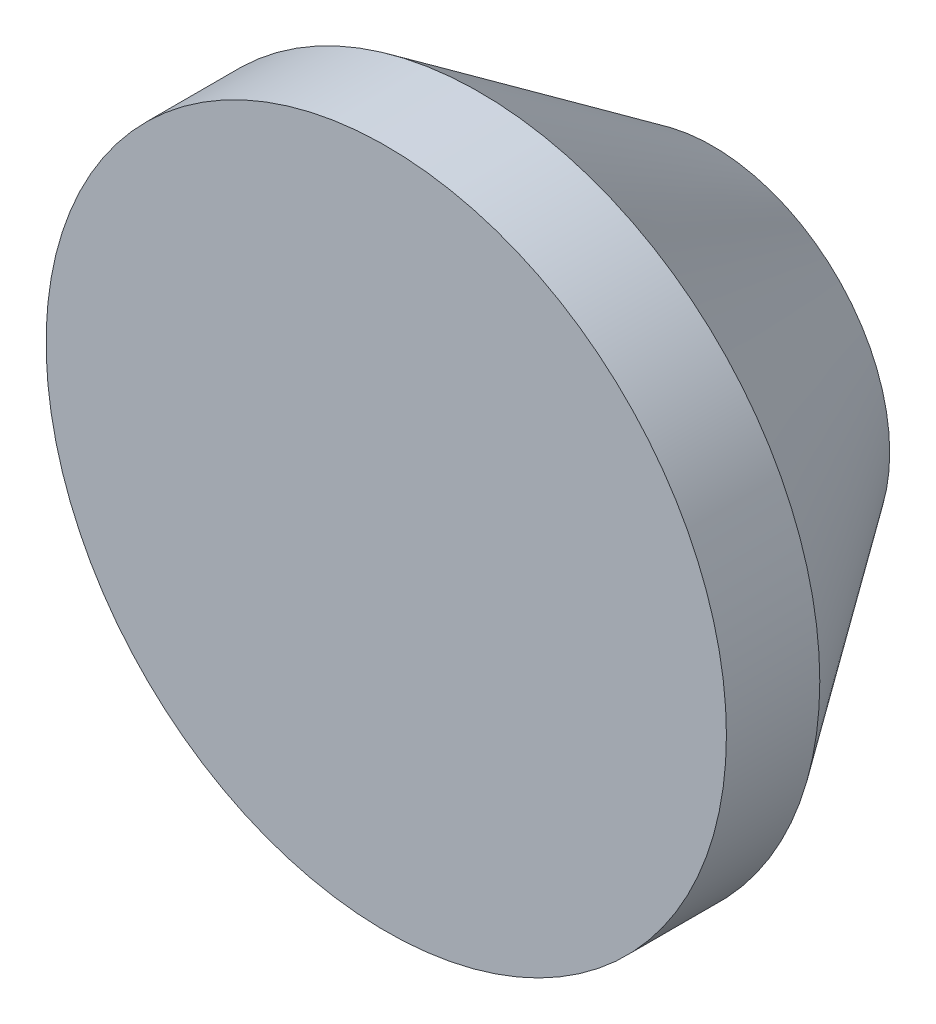
from build123d import *

# Parameters (mm, degrees)
SKETCH1_R           = 12.5
SKETCH1_R_2         = 3
BOSS_EXTRUDE1_DEPTH = 12
SKETCH2_R           = 3
BOSS_EXTRUDE2_DEPTH = 1
CHAMFER1_SIZE       = 6
CHAMFER1_SIZE2      = 8.56888804


with BuildPart() as part:
    # Sketch1 → Boss-Extrude1 (new body)
    with BuildSketch(Plane.XY):
        Circle(SKETCH1_R)
        Circle(SKETCH1_R_2, mode=Mode.SUBTRACT)
    extrude(amount=BOSS_EXTRUDE1_DEPTH)

    # Sketch2 → Boss-Extrude2 (add)
    with BuildSketch(Plane.XY.offset(12)):
        Circle(SKETCH2_R)
    extrude(amount=-BOSS_EXTRUDE2_DEPTH)

    # Chamfer1
    chamfer1_edges = [part.edges().sort_by_distance(p)[0] for p in [
        (-12.5, 0, 0),
    ]]
    chamfer1_side = [part.faces().sort_by_distance(p)[0] for p in [
        (-12.146446609, 0, 0),
    ]]
    chamfer(chamfer1_edges, length=CHAMFER1_SIZE, length2=CHAMFER1_SIZE2, reference=chamfer1_side[0])


solid = part.part
